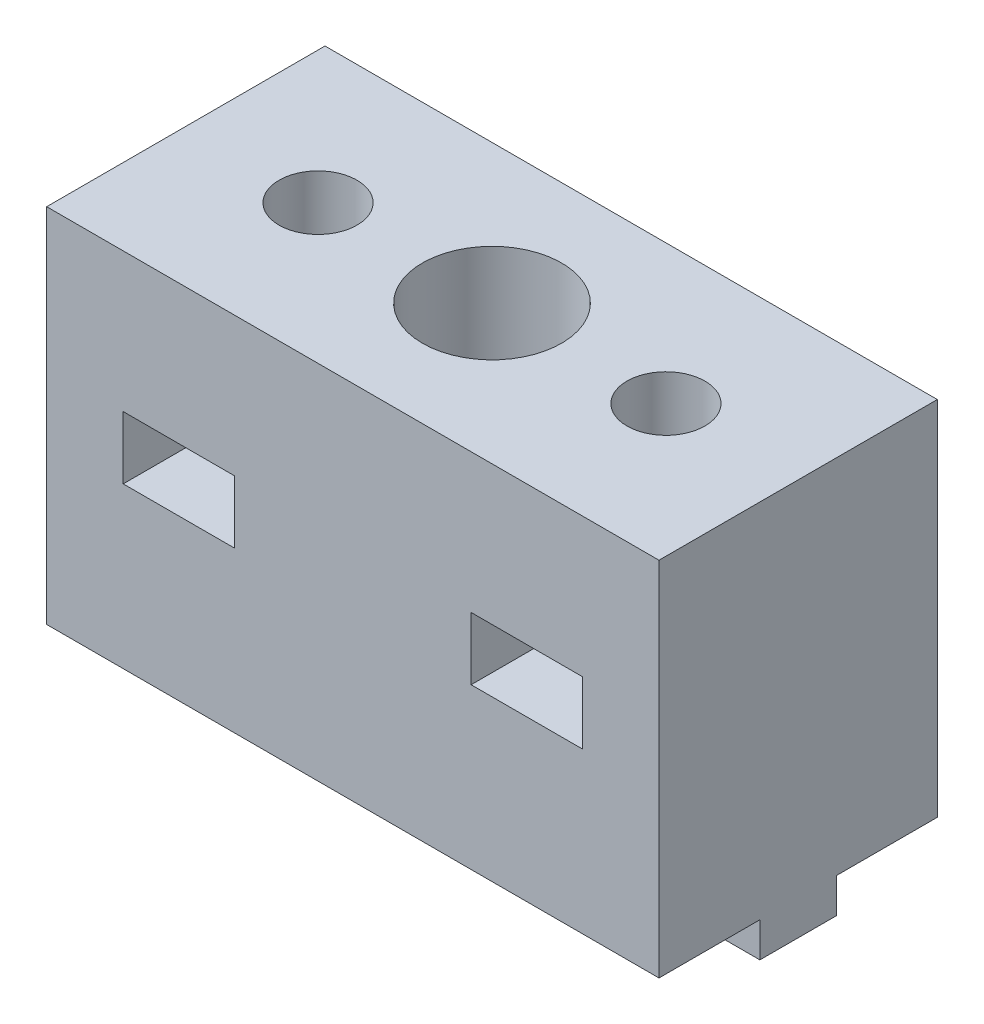
from build123d import *

# Parameters (mm, degrees)
SKETCH1_W           = 44
SKETCH1_H           = 20
BOSS_EXTRUDE1_DEPTH = 26
SKETCH3_W           = 44
SKETCH3_H           = 5.5
BOSS_EXTRUDE5_DEPTH = 2.5
SKETCH2_R           = 2.8
CUT_EXTRUDE1_DEPTH  = 29.5
SKETCH4_R           = 5
CUT_EXTRUDE2_DEPTH  = 21
SKETCH5_W           = 8
SKETCH5_H           = 4.5
CUT_EXTRUDE3_DEPTH  = 21
SKETCH6_W           = 10
SKETCH6_H           = 5.5
CUT_EXTRUDE4_DEPTH  = 2.5


with BuildPart() as part:
    # Sketch1 → Boss-Extrude1 (new body)
    with BuildSketch(Plane(origin=(0, 0, 0), x_dir=(1, 0, 0), z_dir=(0, 1, 0))):
        with Locations((21.30324178, 10)):
            Rectangle(SKETCH1_W, SKETCH1_H)
    extrude(amount=BOSS_EXTRUDE1_DEPTH)

    # Sketch3 → Boss-Extrude5 (add)
    with BuildSketch(Plane.XZ):
        with Locations((21.30324178, -10)):
            Rectangle(SKETCH3_W, SKETCH3_H)
    extrude(amount=BOSS_EXTRUDE5_DEPTH)

    # Sketch2 → Cut-Extrude1 (cut, through all)
    with BuildSketch(Plane(origin=(0, 26, 0), x_dir=(1, 0, 0), z_dir=(0, 1, 0))):
        with Locations((8.80324178, 10)):
            Circle(SKETCH2_R)
        with Locations((33.80324178, 10)):
            Circle(SKETCH2_R)
        with Locations((21.30324178, 10)):
            Circle(SKETCH2_R)
    extrude(amount=-CUT_EXTRUDE1_DEPTH, mode=Mode.SUBTRACT)

    # Sketch4 → Cut-Extrude2 (cut)
    with BuildSketch(Plane(origin=(0, 26, 0), x_dir=(1, 0, 0), z_dir=(0, 1, 0))):
        with Locations((21.30324178, 10)):
            Circle(SKETCH4_R)
    extrude(amount=-CUT_EXTRUDE2_DEPTH, mode=Mode.SUBTRACT)

    # Sketch5 → Cut-Extrude3 (cut, through all)
    with BuildSketch(Plane(origin=(0, 0, -20), x_dir=(-1, 0, 0), z_dir=(0, 0, -1))):
        with Locations((-33.80324178, 13.75)):
            Rectangle(SKETCH5_W, SKETCH5_H)
        with Locations((-8.80324178, 13.75)):
            Rectangle(SKETCH5_W, SKETCH5_H)
    extrude(amount=-CUT_EXTRUDE3_DEPTH, mode=Mode.SUBTRACT)

    # Sketch6 → Cut-Extrude4 (cut)
    with BuildSketch(Plane.XZ.offset(2.5)):
        with Locations((21.30324178, -10)):
            Rectangle(SKETCH6_W, SKETCH6_H)
    extrude(amount=-CUT_EXTRUDE4_DEPTH, mode=Mode.SUBTRACT)


solid = part.part
